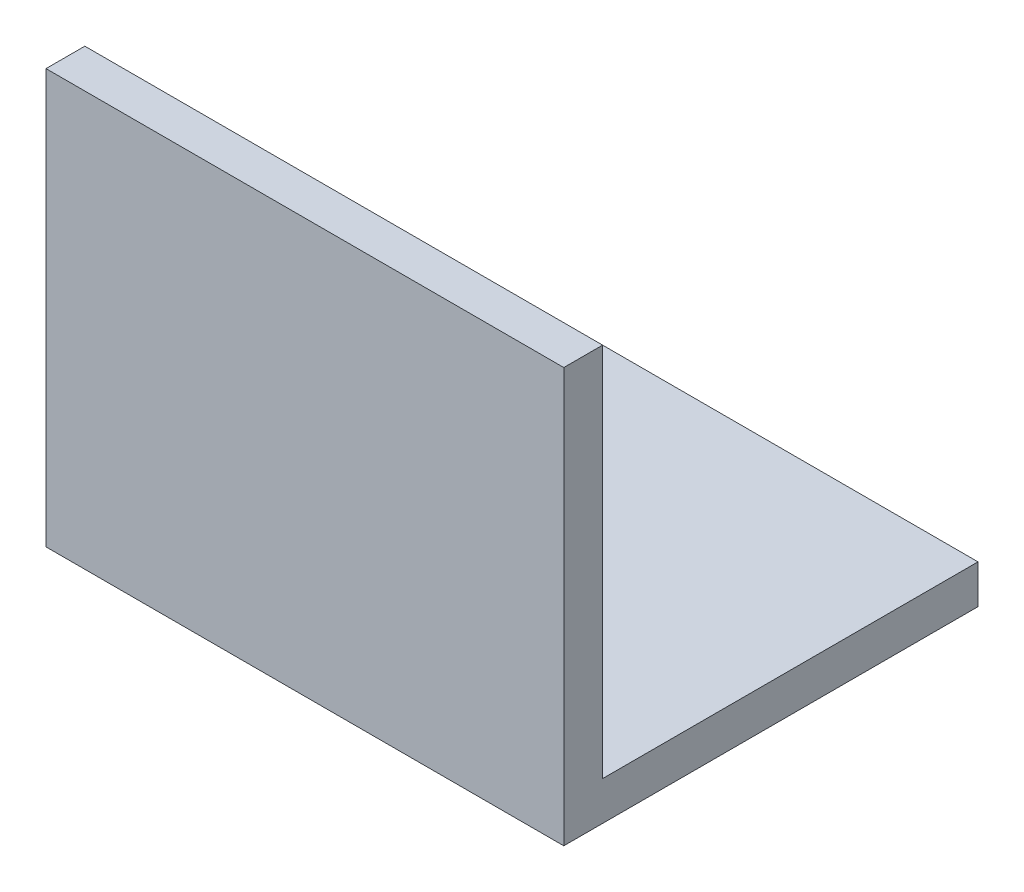
from build123d import *

# Parameters (mm, degrees)
EXTRUDE_1_DEPTH = 40


with BuildPart() as part:
    # Эскиз1 → Вытянуть-Тонкостенный1 (new body)
    with BuildSketch(Plane(origin=(0, 0, 0), x_dir=(0, 0, -1), z_dir=(1, 0, 0))):
        Polygon((0, 32), (0, 0), (32, 0), (32, 3), (3, 3), (3, 32), align=None)
    extrude(amount=EXTRUDE_1_DEPTH)


solid = part.part
